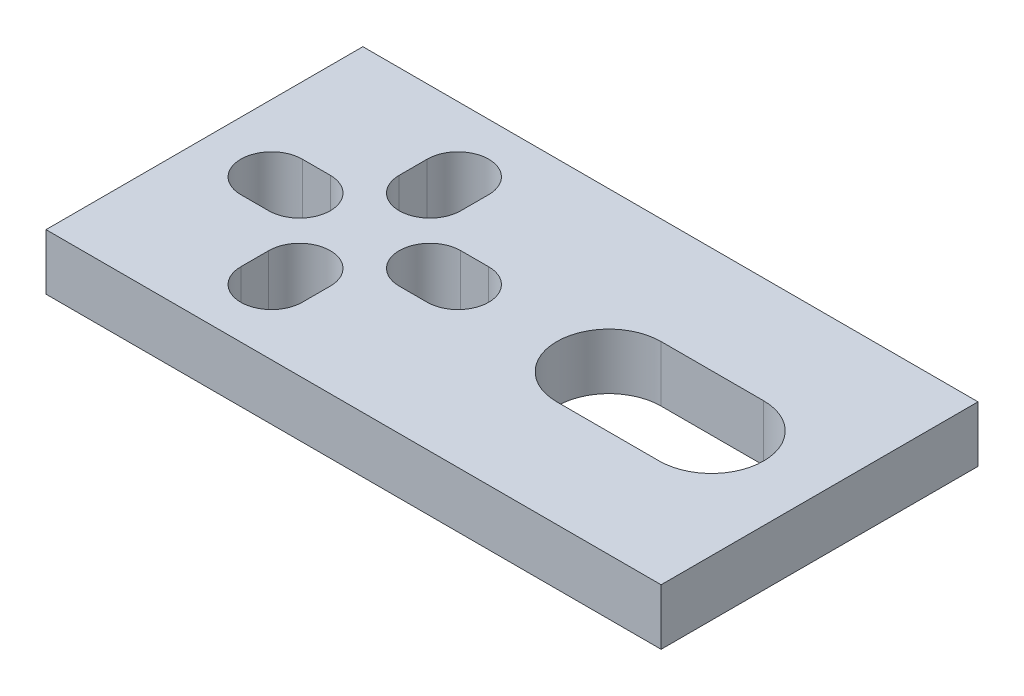
from build123d import *

# Parameters (mm, degrees)
SKETCH1_W           = 33
SKETCH1_H           = 17
BOSS_EXTRUDE1_DEPTH = 3
CUT_EXTRUDE1_DEPTH  = 4


with BuildPart() as part:
    # Sketch1 → Boss-Extrude1 (new body)
    with BuildSketch(Plane(origin=(0, 0, 0), x_dir=(1, 0, 0), z_dir=(0, 1, 0))):
        with Locations((16.5, 8.5)):
            Rectangle(SKETCH1_W, SKETCH1_H)
    extrude(amount=BOSS_EXTRUDE1_DEPTH)

    # Sketch2 → Cut-Extrude1 (cut, through all)
    with BuildSketch(Plane(origin=(0, 3, 0), x_dir=(1, 0, 0), z_dir=(0, 1, 0))):
        with BuildLine():
            Line((21.7, 11.3), (27.2, 11.3))
            ThreePointArc((27.2, 11.3), (30, 8.5), (27.2, 5.7))
            Line((27.2, 5.7), (21.7, 5.7))
            ThreePointArc((21.7, 5.7), (18.9, 8.5), (21.7, 11.3))
        make_face()
        with BuildLine():
            Line((6.95, 12), (6.95, 13.5))
            ThreePointArc((6.95, 13.5), (8.6, 15.15), (10.25, 13.5))
            Line((10.25, 13.5), (10.25, 12))
            ThreePointArc((10.25, 12), (8.6, 10.35), (6.95, 12))
        make_face()
        with BuildLine():
            Line((3.6, 10.15), (5.1, 10.15))
            ThreePointArc((5.1, 10.15), (6.75, 8.5), (5.1, 6.85))
            Line((5.1, 6.85), (3.6, 6.85))
            ThreePointArc((3.6, 6.85), (1.95, 8.5), (3.6, 10.15))
        make_face()
        with BuildLine():
            Line((13.6, 10.15), (12.1, 10.15))
            ThreePointArc((12.1, 10.15), (10.45, 8.5), (12.1, 6.85))
            Line((12.1, 6.85), (13.6, 6.85))
            ThreePointArc((13.6, 6.85), (15.25, 8.5), (13.6, 10.15))
        make_face()
        with BuildLine():
            Line((6.95, 5), (6.95, 3.5))
            ThreePointArc((6.95, 3.5), (8.6, 1.85), (10.25, 3.5))
            Line((10.25, 3.5), (10.25, 5))
            ThreePointArc((10.25, 5), (8.6, 6.65), (6.95, 5))
        make_face()
    extrude(amount=-CUT_EXTRUDE1_DEPTH, mode=Mode.SUBTRACT)


solid = part.part
